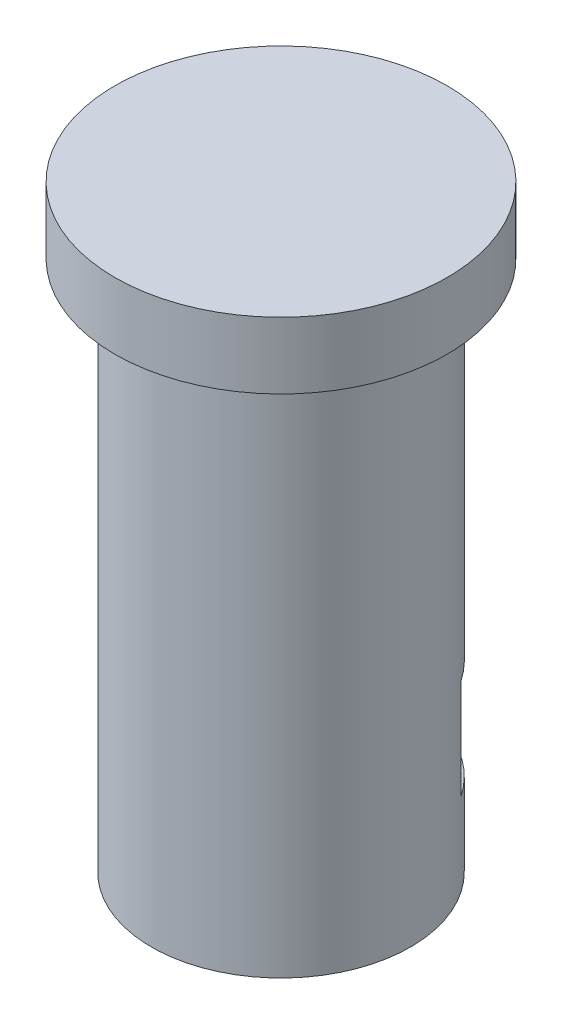
from build123d import *

# Parameters (mm, degrees)
SKETCH1_R               = 5
BOSS_EXTRUDE1_DEPTH     = 2
SKETCH4_R               = 3.9
BOSS_EXTRUDE2_DEPTH     = 16
CUT_EXTRUDE4_DEPTH      = 3
SKETCH3_5_R             = 1.7
CUT_EXTRUDE5_DEPTH      = 3
CUT_EXTRUDE5_DEPTH_BACK = 3.5
SKETCH5_W               = 6.581793069
SKETCH5_H               = 3
CUT_EXTRUDE6_DEPTH      = 6.0375


with BuildPart() as part:
    # Sketch1 → Boss-Extrude1 (new body)
    with BuildSketch(Plane(origin=(0, 0, 0), x_dir=(1, 0, 0), z_dir=(0, 1, 0))):
        Circle(SKETCH1_R)
    extrude(amount=BOSS_EXTRUDE1_DEPTH)

    # Sketch4 → Boss-Extrude2 (add)
    with BuildSketch(Plane(origin=(0, 0, 0), x_dir=(-1, 0, 0), z_dir=(0, -1, 0))):
        Circle(SKETCH4_R)
    extrude(amount=BOSS_EXTRUDE2_DEPTH)

    # Sketch3 → Cut-Extrude4 (cut)
    with BuildSketch(Plane(origin=(0, -13.5, 0), x_dir=(1, 0, 0), z_dir=(0, 1, 0))):
        Polygon((3.225944629, -0.0375), (1.580496362, 2.8125), (-1.710400172, 2.8125), (-3.35584844, -0.0375), (-1.710400172, -2.8875), (1.580496362, -2.8875), align=None)
    extrude(amount=CUT_EXTRUDE4_DEPTH, mode=Mode.SUBTRACT)

    # Sketch3_5 → Cut-Extrude5 (cut, two sides)
    with BuildSketch(Plane(origin=(0, -13.5, 0), x_dir=(1, 0, 0), z_dir=(0, 1, 0))) as cut_extrude5_sk:
        with Locations((-0.064951905, -0.0375)):
            Circle(SKETCH3_5_R)
    extrude(amount=CUT_EXTRUDE5_DEPTH, mode=Mode.SUBTRACT)
    extrude(cut_extrude5_sk.sketch, amount=-CUT_EXTRUDE5_DEPTH_BACK, mode=Mode.SUBTRACT)

    # Sketch5 → Cut-Extrude6 (cut, through all)
    with BuildSketch(Plane.XY.offset(0.0375)):
        with Locations((-0.064951906, -12)):
            Rectangle(SKETCH5_W, SKETCH5_H)
    extrude(amount=-CUT_EXTRUDE6_DEPTH, mode=Mode.SUBTRACT)


solid = part.part
